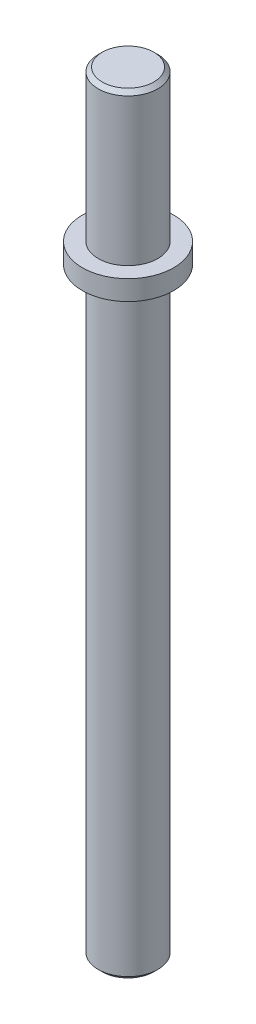
from build123d import *

# Parameters (mm, degrees)
CHAMFER1_SIZE = 0.254


with BuildPart() as part:
    # Sketch1 → Revolve1 (revolve)
    with BuildSketch(Plane.XY):
        Polygon((1.905, 3.048), (1.905, -35.306), (0, -35.306), (0, 13.97), (1.905, 13.97), (1.905, 4.318), (2.921, 4.318), (2.921, 3.048), align=None)
    revolve(axis=Axis((0, 0, 0), (0, 1, 0)))

    # Chamfer1
    chamfer1_edges = [part.edges().sort_by_distance(p)[0] for p in [
        (-1.905, 13.97, 0),
        (-1.905, -35.306, 0),
    ]]
    chamfer(chamfer1_edges, length=CHAMFER1_SIZE)


solid = part.part
